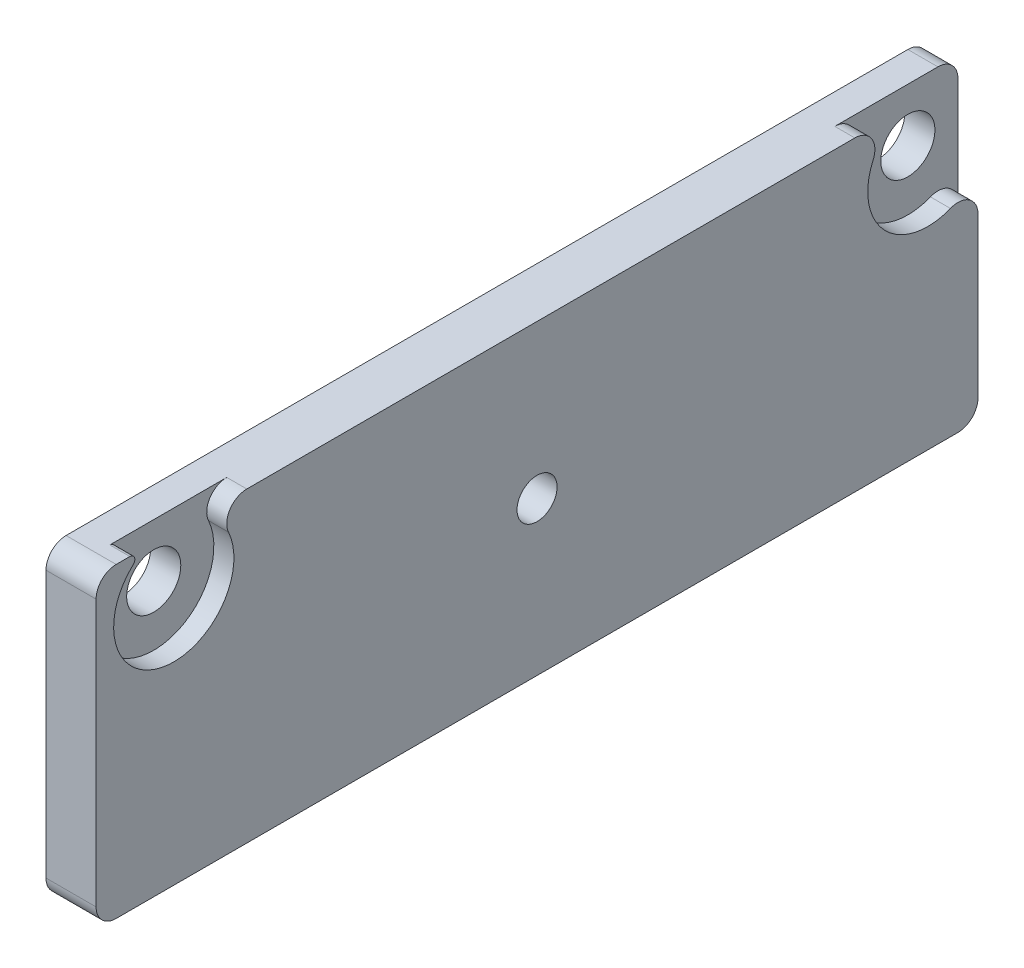
from build123d import *

# Parameters (mm, degrees)
SKETCH1_W                                          = 44
SKETCH1_H                                          = 15.3
SKETCH1_R                                          = 1
BOSS_EXTRUDE1_DEPTH                                = 2.5
CBORE_FOR_M2_5_PAN_HEAD_MACHINE_SCREW1_D           = 2.7
CBORE_FOR_M2_5_PAN_HEAD_MACHINE_SCREW1_CBORE_D     = 6
CBORE_FOR_M2_5_PAN_HEAD_MACHINE_SCREW1_CBORE_DEPTH = 1
CUT_EXTRUDE1_DEPTH                                 = 1
FILLET1_R                                          = 1
FILLET2_R                                          = 0.25


with BuildPart() as part:
    # Sketch1 → Boss-Extrude1 (new body)
    with BuildSketch(Plane(origin=(0, 0, 0), x_dir=(0, 0, -1), z_dir=(1, 0, 0))):
        Rectangle(SKETCH1_W, SKETCH1_H)
        Circle(SKETCH1_R, mode=Mode.SUBTRACT)
    extrude(amount=BOSS_EXTRUDE1_DEPTH)

    # CBORE for M2.5 Pan Head Machine Screw1 (through all)
    with Locations(Plane(origin=(2.5, 0, 0), x_dir=(0, 0, -1), z_dir=(1, 0, 0))):
        with Locations((-18.125, 5), (19.5, 5)):
            CounterBoreHole(CBORE_FOR_M2_5_PAN_HEAD_MACHINE_SCREW1_D / 2, CBORE_FOR_M2_5_PAN_HEAD_MACHINE_SCREW1_CBORE_D / 2, CBORE_FOR_M2_5_PAN_HEAD_MACHINE_SCREW1_CBORE_DEPTH)

    # Sketch5 → Cut-Extrude1 (cut)
    with BuildSketch(Plane(origin=(2.5, 0, 0), x_dir=(0, 0, -1), z_dir=(1, 0, 0))):
        with BuildLine():
            ThreePointArc((22, 6.658312395), (21.515075982, 7.222491571), (20.906236111, 7.65))
            Line((20.906236111, 7.65), (22, 7.65))
            Line((22, 7.65), (22, 6.658312395))
        make_face()
    extrude(amount=-CUT_EXTRUDE1_DEPTH, mode=Mode.SUBTRACT)

    # Fillet1
    fillet1_edges = [part.edges().sort_by_distance(p)[0] for p in [
        (2, 3.341687605, -22),
        (2, 7.65, -18.093763889),
        (2, 7.65, 16.718763889),
        (0.75, 7.65, -22),
        (1.25, -7.65, -22),
        (1.25, -7.65, 22),
        (1.25, 7.65, 22),
    ]]
    fillet(fillet1_edges, radius=FILLET1_R)

    # Fillet2
    fillet2_edges = [part.edges().sort_by_distance(p)[0] for p in [
        (2, 7.65, 19.531236111),
    ]]
    fillet(fillet2_edges, radius=FILLET2_R)


solid = part.part
